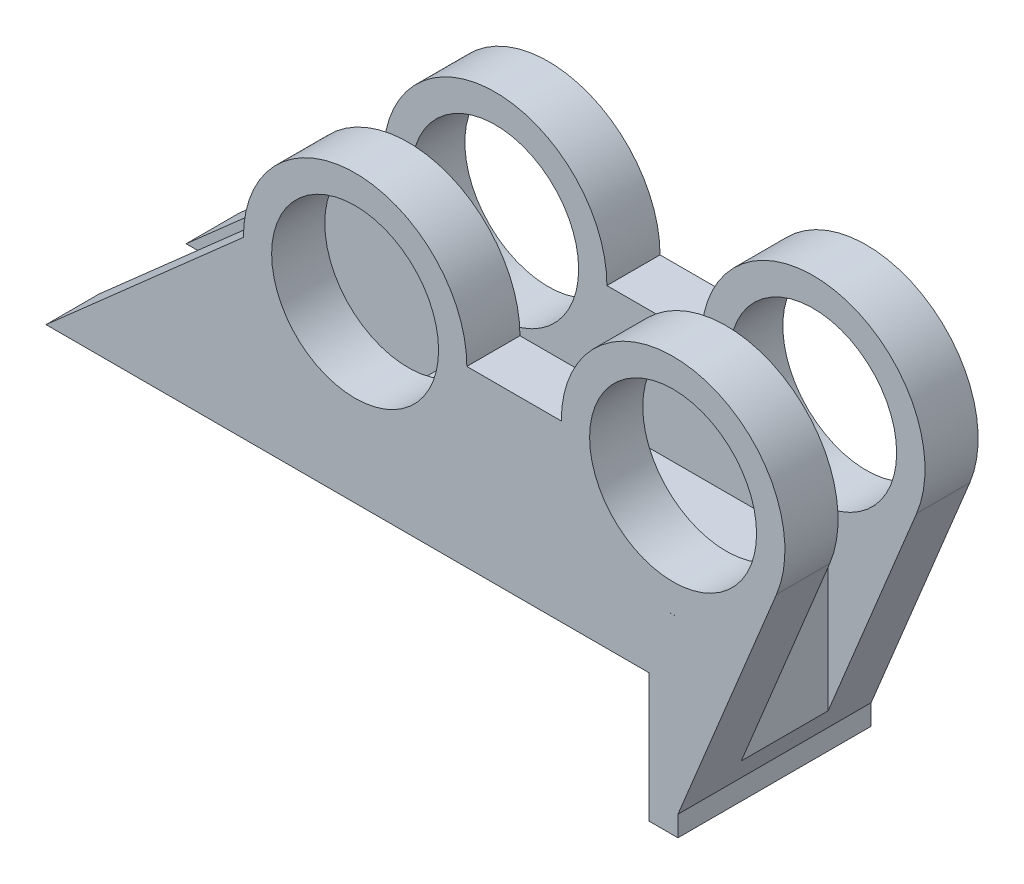
from build123d import *

# Parameters (mm, degrees)
SKETCH1_R                                      = 10.9728
BOSS_EXTRUDE1_DEPTH                            = 25.4
SKETCH2_W                                      = 11.43
SKETCH2_H                                      = 30.40742991
CUT_EXTRUDE1_DEPTH                             = 63.5
CBORE_FOR_8_SOCKET_HEAD_CAP_SCREW2_D           = 4.3053
CBORE_FOR_8_SOCKET_HEAD_CAP_SCREW2_DEPTH       = 7.19576864
CBORE_FOR_8_SOCKET_HEAD_CAP_SCREW2_CBORE_D     = 7.9375
CBORE_FOR_8_SOCKET_HEAD_CAP_SCREW2_CBORE_DEPTH = 4.1656
SKETCH6_W                                      = 7.470933486
SKETCH6_H                                      = 11.420765966
CUT_EXTRUDE2_DEPTH                             = 63.5
SKETCH9_W                                      = 11.43
SKETCH9_H                                      = 7.19576864
CUT_EXTRUDE3_DEPTH                             = 38.1


with BuildPart() as part:
    # Sketch1 → Boss-Extrude1 (new body)
    with BuildSketch(Plane.XY):
        with BuildLine():
            Line((37.182732387, 0.114888998), (37.182732387, 2.802342002))
            Line((37.182732387, 2.802342002), (50.142253344, 34.313558963))
            ThreePointArc((50.142253344, 34.313558963), (39.395041388, 54.329173661), (21.842526976, 39.905698546))
            Line((21.842526976, 39.905698546), (9.430821913, 39.905698546))
            ThreePointArc((9.430821913, 39.905698546), (-5.258087214, 54.594607673), (-19.946996342, 39.905698546))
            Line((-19.946996342, 39.905698546), (-45.891553328, 17.0048778))
            Line((-45.891553328, 17.0048778), (33.346811678, 17.0048778))
            Line((33.346811678, 17.0048778), (33.346811678, 0.114888998))
            Line((33.346811678, 0.114888998), (37.182732387, 0.114888998))
        make_face()
        with BuildLine():
            Line((35.907077172, 25.217162573), (37.182732387, 25.217162573))
            ThreePointArc((37.182732387, 25.217162573), (36.54490478, 25.203320742), (35.907077172, 25.217162573))
        make_face(mode=Mode.SUBTRACT)
        with Locations((-5.258087214, 39.905698546)):
            Circle(SKETCH1_R, mode=Mode.SUBTRACT)
        with Locations((36.54490478, 39.905698546)):
            Circle(SKETCH1_R, mode=Mode.SUBTRACT)
    extrude(amount=BOSS_EXTRUDE1_DEPTH)

    # Sketch2 → Cut-Extrude1 (cut, symmetric)
    with BuildSketch(Plane(origin=(0, 0, 0), x_dir=(0, 0, -1), z_dir=(1, 0, 0))):
        with Locations((-12.7, 39.404361395)):
            Rectangle(SKETCH2_W, SKETCH2_H)
    extrude(amount=CUT_EXTRUDE1_DEPTH, both=True, mode=Mode.SUBTRACT)

    # CBORE for #8 Socket Head Cap Screw2
    with Locations(Plane(origin=(2.23670917, 24.20064644, 12.7), x_dir=(0, 0, 1), z_dir=(0, 1, 0))):
        with Locations((0, 0), (0, 13.971505139)):
            CounterBoreHole(CBORE_FOR_8_SOCKET_HEAD_CAP_SCREW2_D / 2, CBORE_FOR_8_SOCKET_HEAD_CAP_SCREW2_CBORE_D / 2, CBORE_FOR_8_SOCKET_HEAD_CAP_SCREW2_CBORE_DEPTH, depth=CBORE_FOR_8_SOCKET_HEAD_CAP_SCREW2_DEPTH)

    # Sketch6 → Cut-Extrude2 (cut, symmetric)
    with BuildSketch(Plane(origin=(0, 24.20064644, 0), x_dir=(1, 0, 0), z_dir=(0, 1, 0))):
        with Locations((42.247680275, -12.695382983)):
            Rectangle(SKETCH6_W, SKETCH6_H)
    extrude(amount=CUT_EXTRUDE2_DEPTH, both=True, mode=Mode.SUBTRACT)

    # Sketch9 → Cut-Extrude3 (cut)
    with BuildSketch(Plane(origin=(-45.891553328, 0, 0), x_dir=(0, 0, -1), z_dir=(1, 0, 0))):
        with Locations((-12.7, 20.60276212)):
            Rectangle(SKETCH9_W, SKETCH9_H)
    extrude(amount=CUT_EXTRUDE3_DEPTH, mode=Mode.SUBTRACT)


solid = part.part
